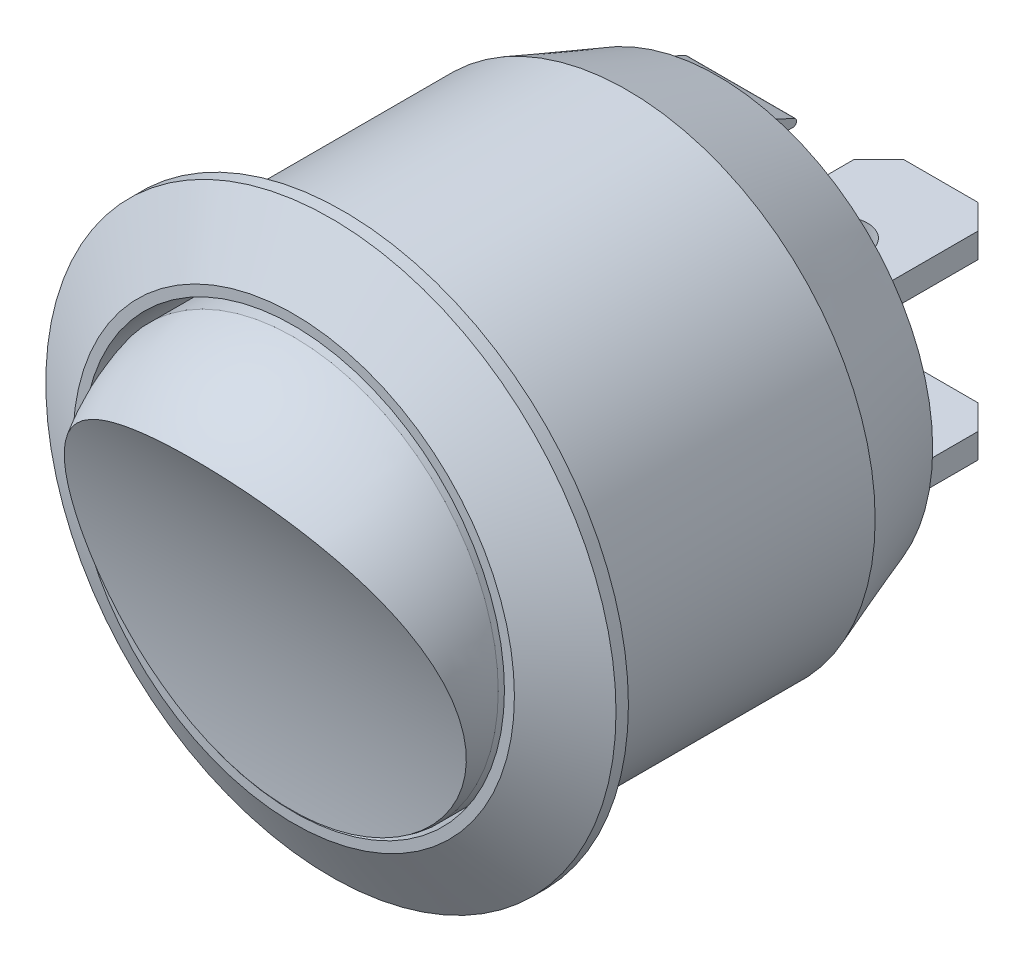
from build123d import *

# Parameters (mm, degrees)
SKETCH1_R                = 10
BOSS_EXTRUDE1_DEPTH      = 15
SKETCH2_R                = 11.5
BOSS_EXTRUDE2_DEPTH      = 2
SKETCH3_R                = 8.5
CUT_EXTRUDE1_DEPTH       = 2
CUT_EXTRUDE2_REACH       = 17
SKETCH4_R                = 8.5
SKETCH4_R_2              = 7
SKETCH5_R                = 10
SKETCH5_W                = 5
SKETCH5_H                = 1
BOSS_EXTRUDE3_DEPTH      = 0.1
BOSS_EXTRUDE3_DEPTH_BACK = 1
SKETCH6_W                = 5
SKETCH6_H                = 1
BOSS_EXTRUDE4_DEPTH      = 9
SKETCH7_R                = 8.25
BOSS_EXTRUDE5_DEPTH      = 6
CUT_EXTRUDE3_DEPTH       = 16
CUT_EXTRUDE3_DEPTH_BACK  = 16
SKETCH10_R               = 1.05
SKETCH10_R_2             = 0.4
CUT_EXTRUDE4_DEPTH       = 13
CHAMFER1_SIZE            = 1
CHAMFER2_SIZE            = 1
BOSS_EXTRUDE8_DEPTH      = 1
BOSS_EXTRUDE9_DEPTH      = 2.2
CHAMFER4_SIZE            = 1.5
CHAMFER4_SIZE2           = 2.598076211


with BuildPart() as part:
    # Sketch1 → Boss-Extrude1 (new body)
    with BuildSketch(Plane.XY):
        Circle(SKETCH1_R)
    extrude(amount=BOSS_EXTRUDE1_DEPTH)

    # Sketch2 → Boss-Extrude2 (add)
    with BuildSketch(Plane.XY.offset(15)):
        Circle(SKETCH2_R)
    extrude(amount=BOSS_EXTRUDE2_DEPTH)

    # Sketch3 → Cut-Extrude1 (cut)
    with BuildSketch(Plane.XY.offset(17)):
        Circle(SKETCH3_R)
    extrude(amount=-CUT_EXTRUDE1_DEPTH, mode=Mode.SUBTRACT)

    # Sketch4 → Cut-Extrude2 (cut, up to next)
    with BuildSketch(Plane.XY.offset(15), mode=Mode.PRIVATE) as cut_extrude2_sk1:
        Circle(SKETCH4_R)
        Circle(SKETCH4_R_2, mode=Mode.SUBTRACT)
    cut_extrude2_tool1 = extrude(cut_extrude2_sk1.sketch, amount=-CUT_EXTRUDE2_REACH, mode=Mode.PRIVATE) & part.part
    add(cut_extrude2_tool1.solids().sort_by_distance((-8.259584, 0, 15))[0], mode=Mode.SUBTRACT)

    # Sketch5 → Boss-Extrude3 (add, two sides)
    with BuildSketch(Plane(origin=(0, 0, 0), x_dir=(-1, 0, 0), z_dir=(0, 0, -1))) as boss_extrude3_sk:
        Circle(SKETCH5_R)
        with Locations((0, 7)):
            Rectangle(SKETCH5_W, SKETCH5_H, mode=Mode.SUBTRACT)
    extrude(amount=BOSS_EXTRUDE3_DEPTH)
    extrude(boss_extrude3_sk.sketch, amount=-BOSS_EXTRUDE3_DEPTH_BACK)

    # Sketch6 → Boss-Extrude4 (add)
    with BuildSketch(Plane(origin=(0, 0, -0.1), x_dir=(-1, 0, 0), z_dir=(0, 0, -1))):
        with Locations((0, -7)):
            Rectangle(SKETCH6_W, SKETCH6_H)
        Rectangle(SKETCH6_W, SKETCH6_H)
    extrude(amount=BOSS_EXTRUDE4_DEPTH)

    # Sketch7 → Boss-Extrude5 (add)
    with BuildSketch(Plane.XY.offset(15)):
        with Locations((0, -0.15)):
            Circle(SKETCH7_R)
    extrude(amount=BOSS_EXTRUDE5_DEPTH)

    # Sketch8 → Cut-Revolve1 (revolve, cut)
    with BuildSketch(Plane(origin=(0, 0, 0), x_dir=(0, 0, -1), z_dir=(1, 0, 0))):
        with BuildLine():
            Line((-17, 8.1), (-21.761349269, 8.1))
            Line((-21.761349269, 8.1), (-21.761349269, 5.797413216))
            Line((-21.761349269, 5.797413216), (-21, 5.797413216))
            ThreePointArc((-21, 5.797413216), (-19.162388314, 7.230803795), (-17, 8.1))
        make_face()
    revolve(axis=Axis((0, -0.15, 21), (0, 0, 1)), mode=Mode.SUBTRACT)

    # Sketch9 → Cut-Extrude3 (cut, two sides)
    with BuildSketch(Plane(origin=(0, 0, 0), x_dir=(0, 0, -1), z_dir=(1, 0, 0))) as cut_extrude3_sk:
        with BuildLine():
            Line((-21, 5.797413216), (-21, -8.374651695))
            Line((-21, -8.374651695), (-17.1, -8.374651695))
            ThreePointArc((-17.1, -8.374651695), (-18.085767141, -1.023272716), (-21, 5.797413216))
        make_face()
    extrude(amount=CUT_EXTRUDE3_DEPTH, mode=Mode.SUBTRACT)
    extrude(cut_extrude3_sk.sketch, amount=-CUT_EXTRUDE3_DEPTH_BACK, mode=Mode.SUBTRACT)

    # Sketch10 → Cut-Extrude4 (cut, through all)
    with BuildSketch(Plane(origin=(0, 0.5, 0), x_dir=(1, 0, 0), z_dir=(0, 1, 0))):
        with Locations((0, 5.1)):
            Circle(SKETCH10_R)
        with Locations((-2.5, 2.1)):
            Circle(SKETCH10_R_2)
        with Locations((2.5, 2.1)):
            Circle(SKETCH10_R_2)
    extrude(amount=-CUT_EXTRUDE4_DEPTH, mode=Mode.SUBTRACT)

    # Chamfer1
    chamfer1_edges = [part.edges().sort_by_distance(p)[0] for p in [
        (2.5, 0, -9.1),
        (-2.5, 0, -9.1),
    ]]
    chamfer(chamfer1_edges, length=CHAMFER1_SIZE)

    # Chamfer2
    chamfer2_edges = [part.edges().sort_by_distance(p)[0] for p in [
        (-2.5, -7, -9.1),
        (2.5, -7, -9.1),
    ]]
    chamfer(chamfer2_edges, length=CHAMFER2_SIZE)

    # Sketch11 → Boss-Extrude8 (add)
    with BuildSketch(Plane(origin=(0, 0.5, 0), x_dir=(1, 0, 0), z_dir=(0, 1, 0))):
        with BuildLine():
            Line((-3.629263342, 1.290449142), (-2.5, 0.318466995))
            Line((-2.5, 0.318466995), (-2.5, 0.1))
            Line((-2.5, 0.1), (-3.382092802, 0.1))
            Line((-3.382092802, 0.1), (-4.076192043, 1.304590563))
            ThreePointArc((-4.076192043, 1.304590563), (-4.0626874, 1.422710807), (-3.945800247, 1.444440068))
            Line((-3.945800247, 1.444440068), (-3.629263342, 1.290449142))
        make_face()
        with BuildLine():
            Line((2.5, 0.318466995), (2.5, 0.1))
            Line((2.5, 0.1), (3.382092802, 0.1))
            Line((3.382092802, 0.1), (4.076192043, 1.304590563))
            ThreePointArc((4.076192043, 1.304590563), (4.0626874, 1.422710807), (3.945800247, 1.444440068))
            Line((3.945800247, 1.444440068), (3.629263342, 1.290449142))
            Line((3.629263342, 1.290449142), (2.5, 0.318466995))
        make_face()
    boss_extrude8 = extrude(amount=-BOSS_EXTRUDE8_DEPTH)

    # Sketch12 → Boss-Extrude9 (add, symmetric)
    with BuildSketch(Plane(origin=(0, 0, 0), x_dir=(0, 0, -1), z_dir=(1, 0, 0))):
        with BuildLine():
            Line((0.1, 0.55), (0.935536489, 0.55))
            ThreePointArc((0.935536489, 0.55), (1.08205668, 0.667877829), (0.998290443, 0.836242215))
            Line((0.998290443, 0.836242215), (0.1, 1.25))
            Line((0.1, 1.25), (0.1, 0.55))
        make_face()
        with BuildLine():
            Line((0.1, -1.25), (0.1, -0.55))
            Line((0.1, -0.55), (0.935536489, -0.55))
            ThreePointArc((0.935536489, -0.55), (1.08205668, -0.667877829), (0.998290443, -0.836242215))
            Line((0.998290443, -0.836242215), (0.1, -1.25))
        make_face()
    boss_extrude9 = extrude(amount=BOSS_EXTRUDE9_DEPTH, both=True)

    # Mirror4: Boss-Extrude8, Boss-Extrude9 across plane
    add(boss_extrude8.mirror(Plane.ZX.offset(-3.5)))
    add(boss_extrude9.mirror(Plane.ZX.offset(-3.5)))

    # Mirror5: Boss-Extrude9 across plane
    add(boss_extrude9.mirror(Plane.ZX.offset(3.5)))

    # Sketch13 → Cut-Revolve2 (revolve, cut)
    with BuildSketch(Plane(origin=(0, 0, 0), x_dir=(0, 0, -1), z_dir=(1, 0, 0))):
        Polygon((1.764077397, 8.06685955), (-3.547182339, 10), (0.1, 10), (1.764077397, 10), align=None)
    revolve(axis=Axis((0, 0, 0), (0, 0, -1)), mode=Mode.SUBTRACT)

    # Chamfer4
    chamfer4_edges = [part.edges().sort_by_distance(p)[0] for p in [
        (-11.5, 0, 17),
    ]]
    chamfer4_side = [part.faces().sort_by_distance(p)[0] for p in [
        (-11.5, 0, 16),
    ]]
    chamfer(chamfer4_edges, length=CHAMFER4_SIZE, length2=CHAMFER4_SIZE2, reference=chamfer4_side[0])


solid = part.part
